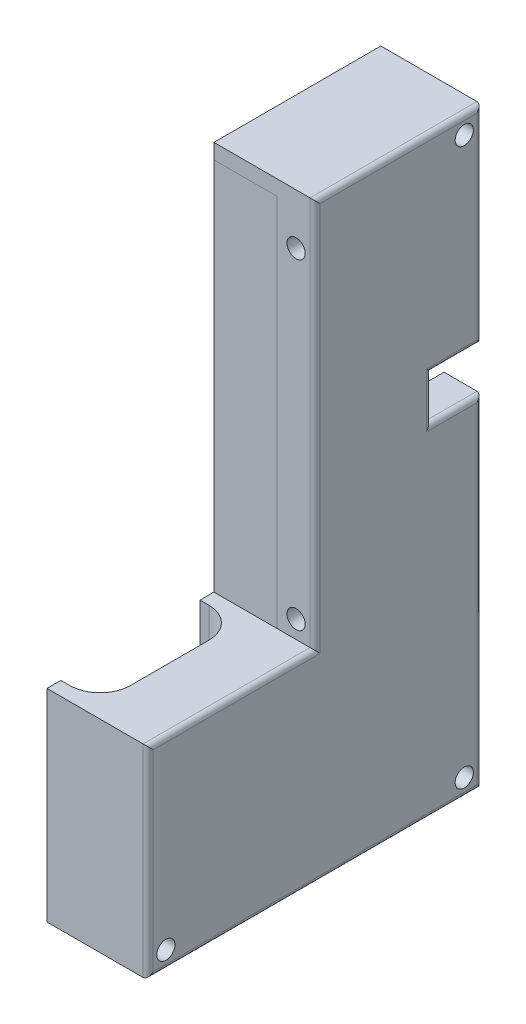
from build123d import *

# Parameters (mm, degrees)
SKETCH_1_W               = 33
SKETCH_1_H               = 25
SKETCH_1_W_2             = 23
SKETCH_1_H_2             = 117
SKETCH_1_W_3             = 10
EXTRUDE_1_DEPTH          = 60
SKETCH_2_W               = 45
SKETCH_2_H               = 62
CUT_EXTRUDE_1_DEPTH      = 10
SKETCH_3_R               = 8.1
CUT_EXTRUDE_2_DEPTH      = 10
SKETCH_4_W               = 45
SKETCH_4_H               = 40
CUT_EXTRUDE_3_DEPTH      = 58.5
SKETCH_5_W               = 60
SKETCH_5_H               = 33
EXTRUDE_2_DEPTH          = 15
EXTRUDE_3_DEPTH          = 7
SKETCH_7_W               = 45
SKETCH_7_H               = 66.5
CUT_EXTRUDE_4_DEPTH      = 20
SKETCH_8_W               = 45
SKETCH_8_H               = 2
EXTRUDE_4_DEPTH          = 89
SKETCH_9_R               = 1.8
CUT_EXTRUDE_5_DEPTH      = 61
SKETCH_10_R              = 1.8
CUT_EXTRUDE_6_DEPTH      = 34
CUT_EXTRUDE_6_DEPTH_BACK = 34
SKETCH_12_R              = 1.8
CUT_EXTRUDE_7_DEPTH      = 3
CUT_EXTRUDE_8_DEPTH      = 40
SKETCH_21_W              = 3
SKETCH_21_H              = 62
CUT_EXTRUDE_9_DEPTH      = 5.5
SKETCH_23_W              = 7.5
SKETCH_23_H              = 8.8
CUT_EXTRUDE_10_DEPTH     = 10
FILLET_1_R               = 1
CUT_EXTRUDE_START        = -12.5
SKETCH_24_W              = 51
SKETCH_24_H              = 4.5
CUT_EXTRUDE_11_DEPTH     = 12.5


with BuildPart() as part:
    # ｽｹｯﾁ1 → ﾎﾞｽ - 押し出し1 (new body)
    with BuildSketch(Plane(origin=(0, 0, 0), x_dir=(0, 0, -1), z_dir=(1, 0, 0))):
        with Locations((-16.5, -12.5)):
            Rectangle(SKETCH_1_W, SKETCH_1_H)
        with Locations((11.5, 33.5)):
            Rectangle(SKETCH_1_W_2, SKETCH_1_H_2)
        with Locations((28, 33.5)):
            Rectangle(SKETCH_1_W_3, SKETCH_1_H_2)
    extrude(amount=EXTRUDE_1_DEPTH)

    # ｽｹｯﾁ2 → ｶｯﾄ - 押し出し1 (cut)
    with BuildSketch(Plane(origin=(0, 0, -33), x_dir=(-1, 0, 0), z_dir=(0, 0, -1))):
        with Locations((-30, 53.5)):
            Rectangle(SKETCH_2_W, SKETCH_2_H)
    extrude(amount=-CUT_EXTRUDE_1_DEPTH, mode=Mode.SUBTRACT)

    # ｽｹｯﾁ3 → ｶｯﾄ - 押し出し2 (cut)
    with BuildSketch(Plane(origin=(0, 92, 0), x_dir=(1, 0, 0), z_dir=(0, 1, 0))):
        with Locations((29, 12.5)):
            Circle(SKETCH_3_R)
    extrude(amount=-CUT_EXTRUDE_2_DEPTH, mode=Mode.SUBTRACT)

    # ｽｹｯﾁ4 → ｶｯﾄ - 押し出し3 (cut)
    with BuildSketch(Plane(origin=(0, 0, -33), x_dir=(-1, 0, 0), z_dir=(0, 0, -1))):
        with Locations((-30, 2.5)):
            Rectangle(SKETCH_4_W, SKETCH_4_H)
    extrude(amount=-CUT_EXTRUDE_3_DEPTH, mode=Mode.SUBTRACT)

    # ｽｹｯﾁ5 → ﾎﾞｽ - 押し出し2 (add)
    with BuildSketch(Plane(origin=(0, 0, 0), x_dir=(1, 0, 0), z_dir=(0, 1, 0))):
        with Locations((30, -16.5)):
            Rectangle(SKETCH_5_W, SKETCH_5_H)
        with BuildLine():
            Line((41.75, -2.75), (16.25, -2.75))
            ThreePointArc((16.25, -2.75), (12.007359313, -4.507359313), (10.25, -8.75))
            Line((10.25, -8.75), (10.25, -24.25))
            ThreePointArc((10.25, -24.25), (12.007359313, -28.492640687), (16.25, -30.25))
            Line((16.25, -30.25), (41.75, -30.25))
            ThreePointArc((41.75, -30.25), (45.992640687, -28.492640687), (47.75, -24.25))
            Line((47.75, -24.25), (47.75, -8.75))
            ThreePointArc((47.75, -8.75), (45.992640687, -4.507359313), (41.75, -2.75))
        make_face(mode=Mode.SUBTRACT)
    extrude(amount=EXTRUDE_2_DEPTH)

    # ｽｹｯﾁ6 → ﾎﾞｽ - 押し出し3 (add)
    with BuildSketch(Plane(origin=(0, 0, 0), x_dir=(1, 0, 0), z_dir=(0, 1, 0))):
        with BuildLine():
            Line((10.381652703, -25.5), (34.75, -25.5))
            Line((34.75, -25.5), (34.75, -7.5))
            Line((34.75, -7.5), (34.75, -2.75))
            Line((34.75, -2.75), (16.25, -2.75))
            ThreePointArc((16.25, -2.75), (12.007359313, -4.507359313), (10.25, -8.75))
            Line((10.25, -8.75), (10.25, -24.25))
            ThreePointArc((10.25, -24.25), (10.283003947, -24.878456927), (10.381652703, -25.5))
        make_face()
        with BuildLine():
            Line((16.25, -30.25), (34.75, -30.25))
            Line((34.75, -30.25), (34.75, -25.5))
            Line((34.75, -25.5), (10.381652703, -25.5))
            ThreePointArc((10.381652703, -25.5), (12.475082782, -28.913689527), (16.25, -30.25))
        make_face()
        with BuildLine():
            Line((34.75, -25.5), (34.75, -30.25))
            Line((34.75, -30.25), (41.75, -30.25))
            ThreePointArc((41.75, -30.25), (42.251757562, -30.228983137), (42.75, -30.166079783))
            Line((42.75, -30.166079783), (42.75, -25.5))
            Line((42.75, -25.5), (34.75, -25.5))
        make_face()
        with BuildLine():
            Line((42.75, -7.5), (42.75, -25.5))
            Line((42.75, -25.5), (47.618347297, -25.5))
            ThreePointArc((47.618347297, -25.5), (47.716996053, -24.878456927), (47.75, -24.25))
            Line((47.75, -24.25), (47.75, -8.75))
            ThreePointArc((47.75, -8.75), (46.332575695, -4.877016654), (42.75, -2.833920217))
            Line((42.75, -2.833920217), (42.75, -7.5))
        make_face()
        with BuildLine():
            Line((47.618347297, -25.5), (42.75, -25.5))
            Line((42.75, -25.5), (42.75, -30.166079783))
            ThreePointArc((42.75, -30.166079783), (45.901701312, -28.581671296), (47.618347297, -25.5))
        make_face()
        with BuildLine():
            Line((34.75, -2.75), (34.75, -7.5))
            Line((34.75, -7.5), (42.75, -7.5))
            Line((42.75, -7.5), (42.75, -2.833920217))
            ThreePointArc((42.75, -2.833920217), (42.251757562, -2.771016863), (41.75, -2.75))
            Line((41.75, -2.75), (34.75, -2.75))
        make_face()
    extrude(amount=EXTRUDE_3_DEPTH)

    # ｽｹｯﾁ7 → ｶｯﾄ - 押し出し4 (cut)
    with BuildSketch(Plane.XY):
        with Locations((30, 55.75)):
            Rectangle(SKETCH_7_W, SKETCH_7_H)
    extrude(amount=-CUT_EXTRUDE_4_DEPTH, mode=Mode.SUBTRACT)

    # ｽｹｯﾁ9 → ｶｯﾄ - 押し出し5 (cut, through all)
    with BuildSketch(Plane.ZY):
        with Locations((-29.5, 88.5)):
            Circle(SKETCH_9_R)
        with Locations((-29.5, -21.5)):
            Circle(SKETCH_9_R)
        with Locations((29.5, -21.5)):
            Circle(SKETCH_9_R)
    extrude(amount=-CUT_EXTRUDE_5_DEPTH, mode=Mode.SUBTRACT)

    # ｽｹｯﾁ10 → ｶｯﾄ - 押し出し6 (cut, two sides)
    with BuildSketch(Plane.XY) as cut_extrude_6_sk:
        with Locations((3.75, 82)):
            Circle(SKETCH_10_R)
        with Locations((56.25, 82)):
            Circle(SKETCH_10_R)
        with Locations((56.25, 18.5)):
            Circle(SKETCH_10_R)
        with Locations((3.75, 18.5)):
            Circle(SKETCH_10_R)
    extrude(amount=CUT_EXTRUDE_6_DEPTH, mode=Mode.SUBTRACT)
    extrude(cut_extrude_6_sk.sketch, amount=-CUT_EXTRUDE_6_DEPTH_BACK, mode=Mode.SUBTRACT)

    # ｽｹｯﾁ12 → ｶｯﾄ - 押し出し7 (cut)
    with BuildSketch(Plane(origin=(0, 0, -23), x_dir=(-1, 0, 0), z_dir=(0, 0, -1))):
        with Locations((-49, 81.5)):
            Circle(SKETCH_12_R)
        with Locations((-11, 81.5)):
            Circle(SKETCH_12_R)
        with Locations((-11, 39.5)):
            Circle(SKETCH_12_R)
        with Locations((-49, 39.5)):
            Circle(SKETCH_12_R)
    extrude(amount=-CUT_EXTRUDE_7_DEPTH, mode=Mode.SUBTRACT)


with BuildPart() as body_2:
    # ｽｹｯﾁ8 → ﾎﾞｽ - 押し出し4 (new body)
    with BuildSketch(Plane(origin=(0, 89, 0), x_dir=(-1, 0, 0), z_dir=(0, -1, 0))):
        with Locations((-30, 1)):
            Rectangle(SKETCH_8_W, SKETCH_8_H)
    extrude(amount=EXTRUDE_4_DEPTH)


with BuildPart() as cut_extrude_8_tool:
    # ｽｹｯﾁ19 → ｶｯﾄ - 押し出し8 (new body)
    with BuildSketch(Plane.ZY):
        Polygon((33, -25), (33, 15), (0, 15), (0, 92), (-33, 92), (-33, -25), align=None)
    extrude(amount=-CUT_EXTRUDE_8_DEPTH)


with BuildPart() as part_1:
    add(part.part)

    # ｶｯﾄ - 押し出し8: cut by cut_extrude_8_tool
    add(cut_extrude_8_tool.part, mode=Mode.SUBTRACT)

    # ｽｹｯﾁ21 → ｶｯﾄ - 押し出し9 (cut)
    with BuildSketch(Plane.ZY.offset(-40)):
        with Locations((-21.5, 53.5)):
            Rectangle(SKETCH_21_W, SKETCH_21_H)
    extrude(amount=-CUT_EXTRUDE_9_DEPTH, mode=Mode.SUBTRACT)

    # ｽｹｯﾁ23 → ｶｯﾄ - 押し出し10 (cut)
    with BuildSketch(Plane(origin=(0, 0, -33), x_dir=(-1, 0, 0), z_dir=(0, 0, -1))):
        with Locations((-56.25, 46.8)):
            Rectangle(SKETCH_23_W, SKETCH_23_H)
    extrude(amount=-CUT_EXTRUDE_10_DEPTH, mode=Mode.SUBTRACT)

    # ﾌｨﾚｯﾄ1
    fillet_1_edges = [part_1.edges().sort_by_distance(p)[0] for p in [
        (60, -5, 33),
        (60, -25, 0),
        (60, 71.6, -33),
        (60, 92, -16.5),
        (60, 8.7, -33),
        (60, 46.8, -23),
        (60, 42.4, -28),
        (60, 51.2, -28),
        (60, 53.5, 0),
        (60, 15, 16.5),
    ]]
    fillet(fillet_1_edges, radius=FILLET_1_R)

    # ｽｹｯﾁ24 → ｶｯﾄ - 押し出し11 (cut)
    with BuildSketch(Plane.ZY.offset(-40).offset(CUT_EXTRUDE_START)):
        with Locations((0, -19.75)):
            Rectangle(SKETCH_24_W, SKETCH_24_H)
    extrude(amount=CUT_EXTRUDE_11_DEPTH, mode=Mode.SUBTRACT)


with BuildPart() as body_2_1:
    add(body_2.part)

    # ｶｯﾄ - 押し出し8: cut by cut_extrude_8_tool
    add(cut_extrude_8_tool.part, mode=Mode.SUBTRACT)


solid = Compound([part_1.part, body_2_1.part])
